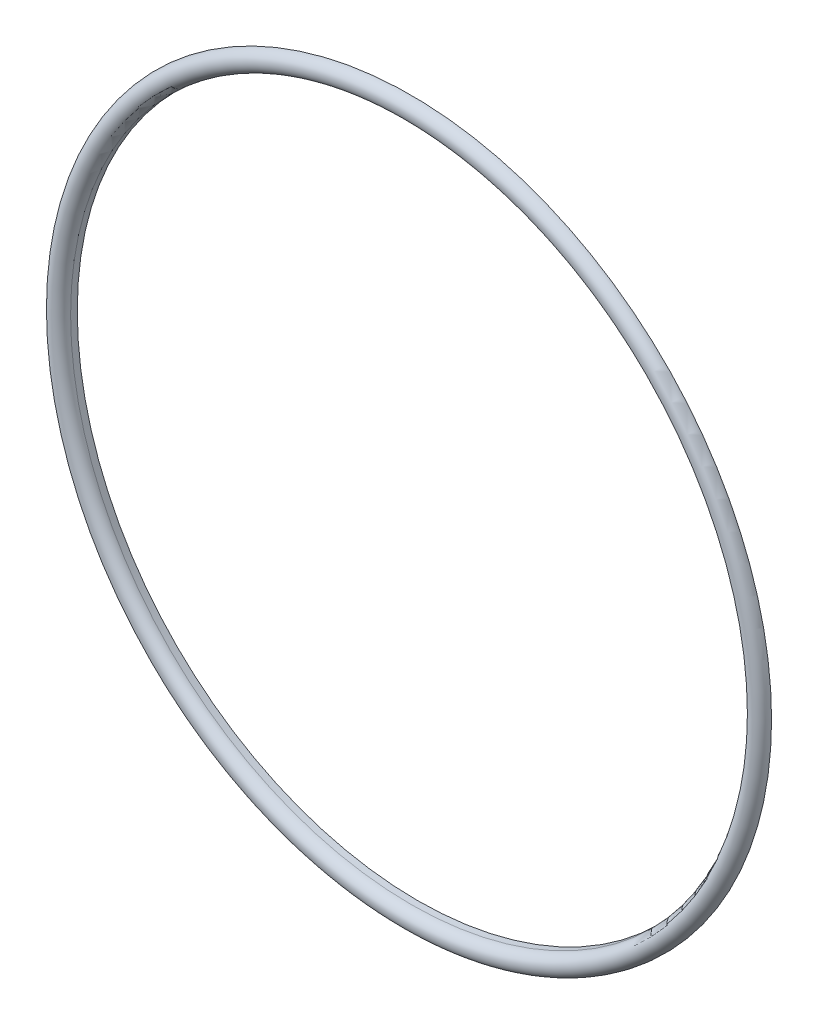
from build123d import *


with BuildPart() as part:
    # Sketch2 → Revolve1 (revolve)
    with BuildSketch(Plane(origin=(0, 0, 0), x_dir=(0, 0, -1), z_dir=(1, 0, 0))):
        with BuildLine():
            Line((0, 54), (0, 52.5))
            Line((0, 52.5), (1, 52.5))
            Line((1, 52.5), (1, 51))
            Line((1, 51), (0, 51))
            ThreePointArc((0, 51), (-1.5, 52.5), (0, 54))
        make_face()
    revolve(axis=Axis((0, 0, 0), (0, 0, 1)))


solid = part.part
